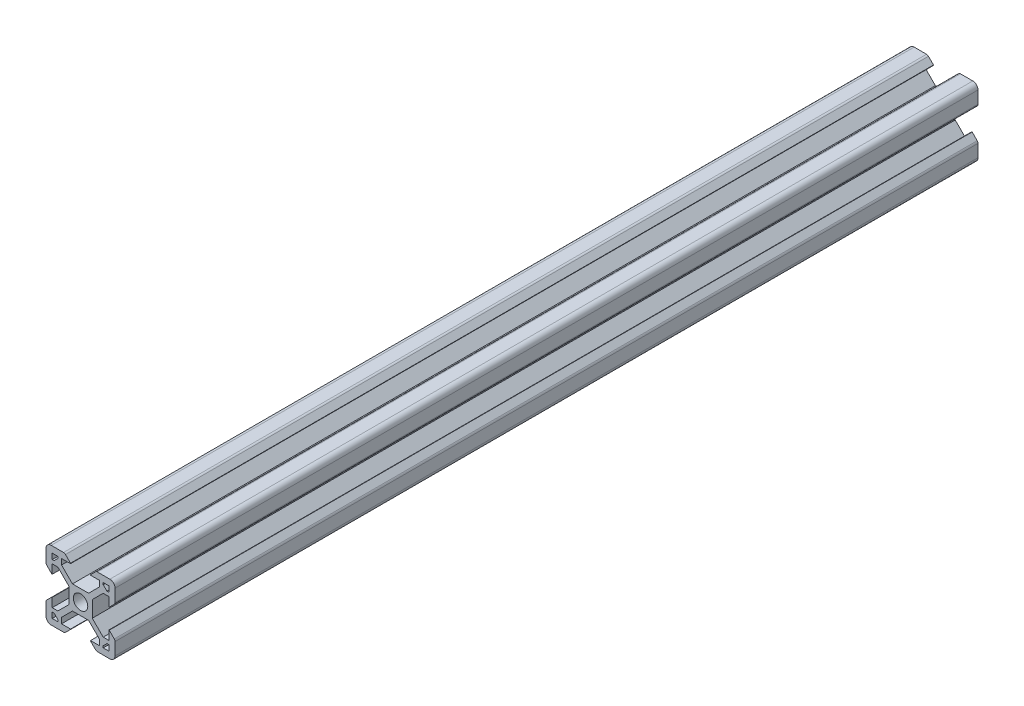
from build123d import *

# Parameters (mm, degrees)
SKETCH6_R           = 2.1
BOSS_EXTRUDE1_DEPTH = 250


with BuildPart() as part:
    # Sketch6 → Boss-Extrude1 (new body)
    with BuildSketch(Plane.XY):
        with BuildLine():
            Line((-3.4, -2.339339828), (-3.4, 2.339339828))
            Line((-3.4, 2.339339828), (-6.560660172, 5.5))
            Line((-6.560660172, 5.5), (-8.2, 5.5))
            Line((-8.2, 5.5), (-8.2, 2.89))
            Line((-8.2, 2.89), (-8.31, 2.89))
            Line((-8.31, 2.89), (-9.768614357, 4.348614357))
            ThreePointArc((-9.768614357, 4.348614357), (-9.939864831, 4.604908803), (-10, 4.907228714))
            Line((-10, 4.907228714), (-10, 8.5))
            ThreePointArc((-10, 8.5), (-9.560660172, 9.560660172), (-8.5, 10))
            Line((-8.5, 10), (-4.907228714, 10))
            ThreePointArc((-4.907228714, 10), (-4.604908803, 9.939864831), (-4.348614357, 9.768614357))
            Line((-4.348614357, 9.768614357), (-2.89, 8.31))
            Line((-2.89, 8.31), (-2.89, 8.2))
            Line((-2.89, 8.2), (-5.5, 8.2))
            Line((-5.5, 8.2), (-5.5, 6.560660172))
            Line((-5.5, 6.560660172), (-2.339339828, 3.4))
            Line((-2.339339828, 3.4), (2.339339828, 3.4))
            Line((2.339339828, 3.4), (5.5, 6.560660172))
            Line((5.5, 6.560660172), (5.5, 8.2))
            Line((5.5, 8.2), (2.89, 8.2))
            Line((2.89, 8.2), (2.89, 8.31))
            Line((2.89, 8.31), (4.348614357, 9.768614357))
            ThreePointArc((4.348614357, 9.768614357), (4.604908803, 9.939864831), (4.907228714, 10))
            Line((4.907228714, 10), (8.5, 10))
            ThreePointArc((8.5, 10), (9.560660172, 9.560660172), (10, 8.5))
            Line((10, 8.5), (10, 4.907228714))
            ThreePointArc((10, 4.907228714), (9.939864831, 4.604908803), (9.768614357, 4.348614357))
            Line((9.768614357, 4.348614357), (8.31, 2.89))
            Line((8.31, 2.89), (8.2, 2.89))
            Line((8.2, 2.89), (8.2, 5.5))
            Line((8.2, 5.5), (6.560660172, 5.5))
            Line((6.560660172, 5.5), (3.4, 2.339339828))
            Line((3.4, 2.339339828), (3.4, -2.339339828))
            Line((3.4, -2.339339828), (6.560660172, -5.5))
            Line((6.560660172, -5.5), (8.2, -5.5))
            Line((8.2, -5.5), (8.2, -2.89))
            Line((8.2, -2.89), (8.31, -2.89))
            Line((8.31, -2.89), (9.768614357, -4.348614357))
            ThreePointArc((9.768614357, -4.348614357), (9.939864831, -4.604908803), (10, -4.907228714))
            Line((10, -4.907228714), (10, -8.5))
            ThreePointArc((10, -8.5), (9.560660172, -9.560660172), (8.5, -10))
            Line((8.5, -10), (4.907228714, -10))
            ThreePointArc((4.907228714, -10), (4.604908803, -9.939864831), (4.348614357, -9.768614357))
            Line((4.348614357, -9.768614357), (2.89, -8.31))
            Line((2.89, -8.31), (2.89, -8.2))
            Line((2.89, -8.2), (5.5, -8.2))
            Line((5.5, -8.2), (5.5, -6.560660172))
            Line((5.5, -6.560660172), (2.339339828, -3.4))
            Line((2.339339828, -3.4), (-2.339339828, -3.4))
            Line((-2.339339828, -3.4), (-5.5, -6.560660172))
            Line((-5.5, -6.560660172), (-5.5, -8.2))
            Line((-5.5, -8.2), (-2.89, -8.2))
            Line((-2.89, -8.2), (-2.89, -8.31))
            Line((-2.89, -8.31), (-4.348614357, -9.768614357))
            ThreePointArc((-4.348614357, -9.768614357), (-4.604908803, -9.939864831), (-4.907228714, -10))
            Line((-4.907228714, -10), (-8.5, -10))
            ThreePointArc((-8.5, -10), (-9.560660172, -9.560660172), (-10, -8.5))
            Line((-10, -8.5), (-10, -4.907228714))
            ThreePointArc((-10, -4.907228714), (-9.939864831, -4.604908803), (-9.768614357, -4.348614357))
            Line((-9.768614357, -4.348614357), (-8.31, -2.89))
            Line((-8.31, -2.89), (-8.2, -2.89))
            Line((-8.2, -2.89), (-8.2, -5.5))
            Line((-8.2, -5.5), (-6.560660172, -5.5))
            Line((-6.560660172, -5.5), (-3.4, -2.339339828))
        make_face()
        Circle(SKETCH6_R, mode=Mode.SUBTRACT)
        Polygon((-7.66, 6.57), (-6.57, 7.66), (-6.57, 8.2), (-8.2, 8.2), (-8.2, 6.57), align=None, mode=Mode.SUBTRACT)
        Polygon((8.2, 6.57), (7.66, 6.57), (6.57, 7.66), (6.57, 8.2), (8.2, 8.2), align=None, mode=Mode.SUBTRACT)
        Polygon((7.66, -6.57), (6.57, -7.66), (6.57, -8.2), (8.2, -8.2), (8.2, -6.57), align=None, mode=Mode.SUBTRACT)
        Polygon((-8.2, -6.57), (-7.66, -6.57), (-6.57, -7.66), (-6.57, -8.2), (-8.2, -8.2), align=None, mode=Mode.SUBTRACT)
    extrude(amount=-BOSS_EXTRUDE1_DEPTH)


solid = part.part
